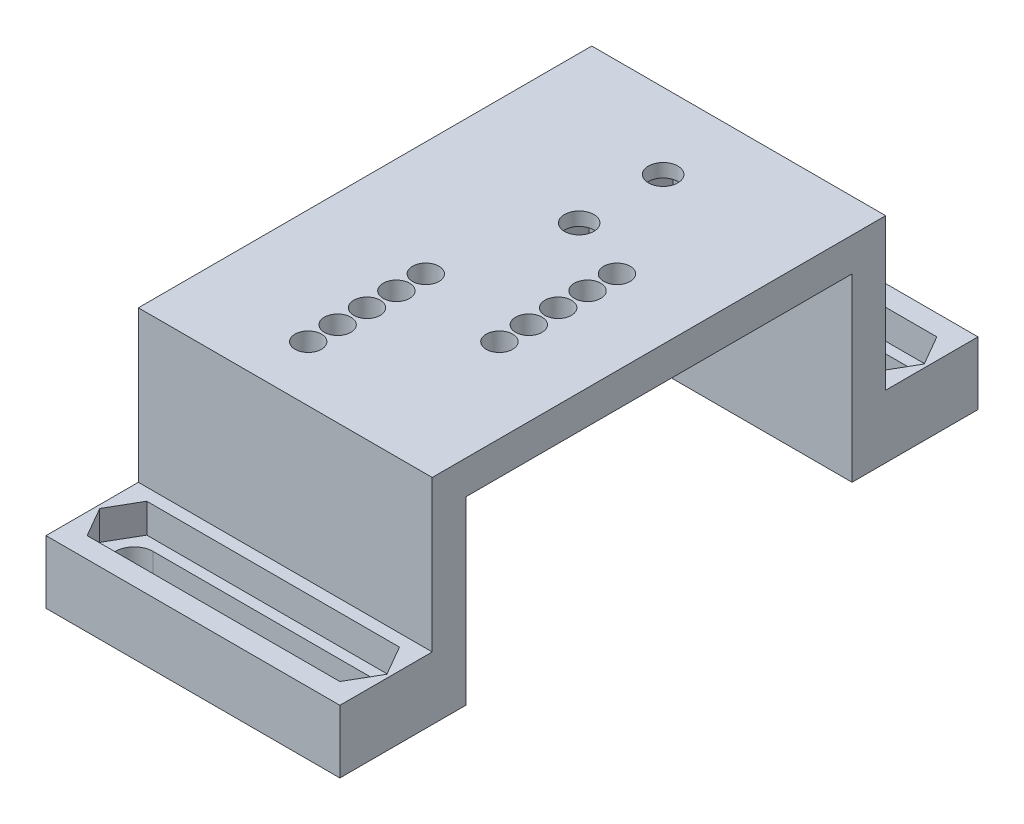
from build123d import *

# Parameters (mm, degrees)
SALIENTE_EXTRUIR1_DEPTH = 35
CORTAR_EXTRUIR1_DEPTH   = 8.5
CROQUIS3_R              = 1.75
CORTAR_EXTRUIR2_DEPTH   = 26.5
CORTAR_EXTRUIR3_DEPTH   = 2.4
CORTAR_EXTRUIR4_DEPTH   = 3.5
CROQUIS8_R              = 1.575
CORTAR_EXTRUIR6_DEPTH   = 5


with BuildPart() as part:
    # Croquis1 → Saliente-Extruir1 (new body)
    with BuildSketch(Plane(origin=(0, 0, 0), x_dir=(0, 0, -1), z_dir=(1, 0, 0))):
        Polygon((-38, -18), (-27, -18), (-27, 0), (27, 0), (27, -18), (38, -18), (38, -25.5), (23, -25.5), (23, -4), (-23, -4), (-23, -25.5), (-38, -25.5), align=None)
    extrude(amount=SALIENTE_EXTRUIR1_DEPTH)

    # Croquis2 → Cortar-Extruir1 (cut, through all)
    with BuildSketch(Plane(origin=(0, -18, 0), x_dir=(1, 0, 0), z_dir=(0, 1, 0))):
        with BuildLine():
            Line((4.5, 34.25), (30.5, 34.25))
            ThreePointArc((30.5, 34.25), (32.75, 32), (30.5, 29.75))
            Line((30.5, 29.75), (4.5, 29.75))
            ThreePointArc((4.5, 29.75), (2.25, 32), (4.5, 34.25))
        make_face()
        with BuildLine():
            Line((4.5, -29.75), (30.5, -29.75))
            ThreePointArc((30.5, -29.75), (32.75, -32), (30.5, -34.25))
            Line((30.5, -34.25), (4.5, -34.25))
            ThreePointArc((4.5, -34.25), (2.25, -32), (4.5, -29.75))
        make_face()
    extrude(amount=-CORTAR_EXTRUIR1_DEPTH, mode=Mode.SUBTRACT)

    # Croquis3 → Cortar-Extruir2 (cut, through all)
    with BuildSketch(Plane(origin=(0, 0, 0), x_dir=(1, 0, 0), z_dir=(0, 1, 0))):
        with Locations((17.5, 18)):
            Circle(CROQUIS3_R)
        with Locations((17.5, 8)):
            Circle(CROQUIS3_R)
    extrude(amount=-CORTAR_EXTRUIR2_DEPTH, mode=Mode.SUBTRACT)

    # Croquis4 → Cortar-Extruir3 (cut)
    with BuildSketch(Plane.XZ.offset(4)):
        Polygon((20.675426481, -8), (19.08771324, -5.25), (15.91228676, -5.25), (14.324573519, -8), (15.91228676, -10.75), (19.08771324, -10.75), align=None)
        Polygon((20.675426481, -18), (19.08771324, -15.25), (15.91228676, -15.25), (14.324573519, -18), (15.91228676, -20.75), (19.08771324, -20.75), align=None)
    extrude(amount=-CORTAR_EXTRUIR3_DEPTH, mode=Mode.SUBTRACT)

    # Croquis5 → Cortar-Extruir4 (cut)
    with BuildSketch(Plane.XZ.offset(18)):
        Polygon((0.400813089, -32), (2.450406544, -28.45), (32.549593456, -28.45), (34.599186911, -32), (32.549593456, -35.55), (2.450406544, -35.55), align=None)
        Polygon((0.400813089, 32), (2.450406544, 28.45), (32.549593456, 28.45), (34.599186911, 32), (32.549593456, 35.55), (2.450406544, 35.55), align=None)
    extrude(amount=CORTAR_EXTRUIR4_DEPTH, mode=Mode.SUBTRACT)

    # Croquis8 → Cortar-Extruir6 (cut, through all)
    with BuildSketch(Plane.XZ.offset(4)):
        with Locations((25, 9)):
            Circle(CROQUIS8_R)
        with Locations((13.615580823, 20.384419177)):
            Circle(CROQUIS8_R)
        with Locations((13.615580823, 16.884419177)):
            Circle(CROQUIS8_R)
        with Locations((25, 5.5)):
            Circle(CROQUIS8_R)
        with Locations((13.615580823, 13.384419177)):
            Circle(CROQUIS8_R)
        with Locations((25, 2)):
            Circle(CROQUIS8_R)
        with Locations((13.615580823, 9.884419177)):
            Circle(CROQUIS8_R)
        with Locations((25, -1.5)):
            Circle(CROQUIS8_R)
        with Locations((13.615580823, 6.384419177)):
            Circle(CROQUIS8_R)
        with Locations((25, -5)):
            Circle(CROQUIS8_R)
    extrude(amount=-CORTAR_EXTRUIR6_DEPTH, mode=Mode.SUBTRACT)


solid = part.part
